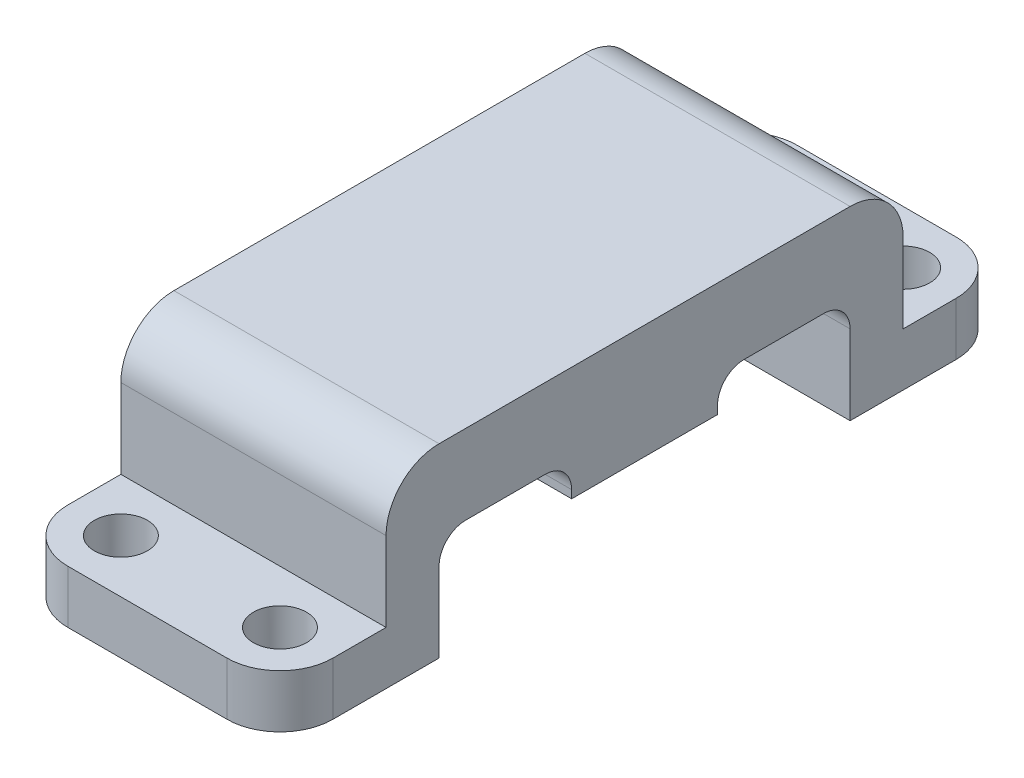
from build123d import *

# Parameters (mm, degrees)
BOSS_EXTRUDE1_DEPTH     = 10
FILLET1_R               = 2
SKETCH2_R               = 1
CUT_EXTRUDE1_DEPTH      = 6
CUT_EXTRUDE1_DEPTH_BACK = 3
FILLET2_R               = 1


with BuildPart() as part:
    # Sketch1 → Boss-Extrude1 (new body)
    with BuildSketch(Plane(origin=(0, 0, 0), x_dir=(0, 0, -1), z_dir=(1, 0, 0))):
        Polygon((-2.75, 0), (-7.75, 0), (-7.75, -4), (-13.75, -4), (-13.75, -2), (-9.75, -2), (-9.75, 3), (9.75, 3), (9.75, -2), (13.75, -2), (13.75, -4), (7.75, -4), (7.75, 0), (2.75, 0), (2.75, -1.3), (-2.75, -1.3), align=None)
    extrude(amount=BOSS_EXTRUDE1_DEPTH)

    # Fillet1
    fillet1_edges = [part.edges().sort_by_distance(p)[0] for p in [
        (0, -3, 13.75),
        (0, -3, -13.75),
        (5, 3, 9.75),
        (5, 3, -9.75),
        (10, -3, -13.75),
        (10, -3, 13.75),
    ]]
    fillet(fillet1_edges, radius=FILLET1_R)

    # Sketch2 → Cut-Extrude1 (cut, two sides)
    with BuildSketch(Plane(origin=(0, -2, 0), x_dir=(1, 0, 0), z_dir=(0, 1, 0))) as cut_extrude1_sk:
        with Locations((8, -11.75)):
            Circle(SKETCH2_R)
        with Locations((2, -11.75)):
            Circle(SKETCH2_R)
        with Locations((2, 11.75)):
            Circle(SKETCH2_R)
        with Locations((8, 11.75)):
            Circle(SKETCH2_R)
    extrude(amount=CUT_EXTRUDE1_DEPTH, mode=Mode.SUBTRACT)
    extrude(cut_extrude1_sk.sketch, amount=-CUT_EXTRUDE1_DEPTH_BACK, mode=Mode.SUBTRACT)

    # Fillet2
    fillet2_edges = [part.edges().sort_by_distance(p)[0] for p in [
        (5, 0, 2.75),
        (5, 0, 7.75),
        (5, 0, -7.75),
        (5, 0, -2.75),
    ]]
    fillet(fillet2_edges, radius=FILLET2_R)


solid = part.part
